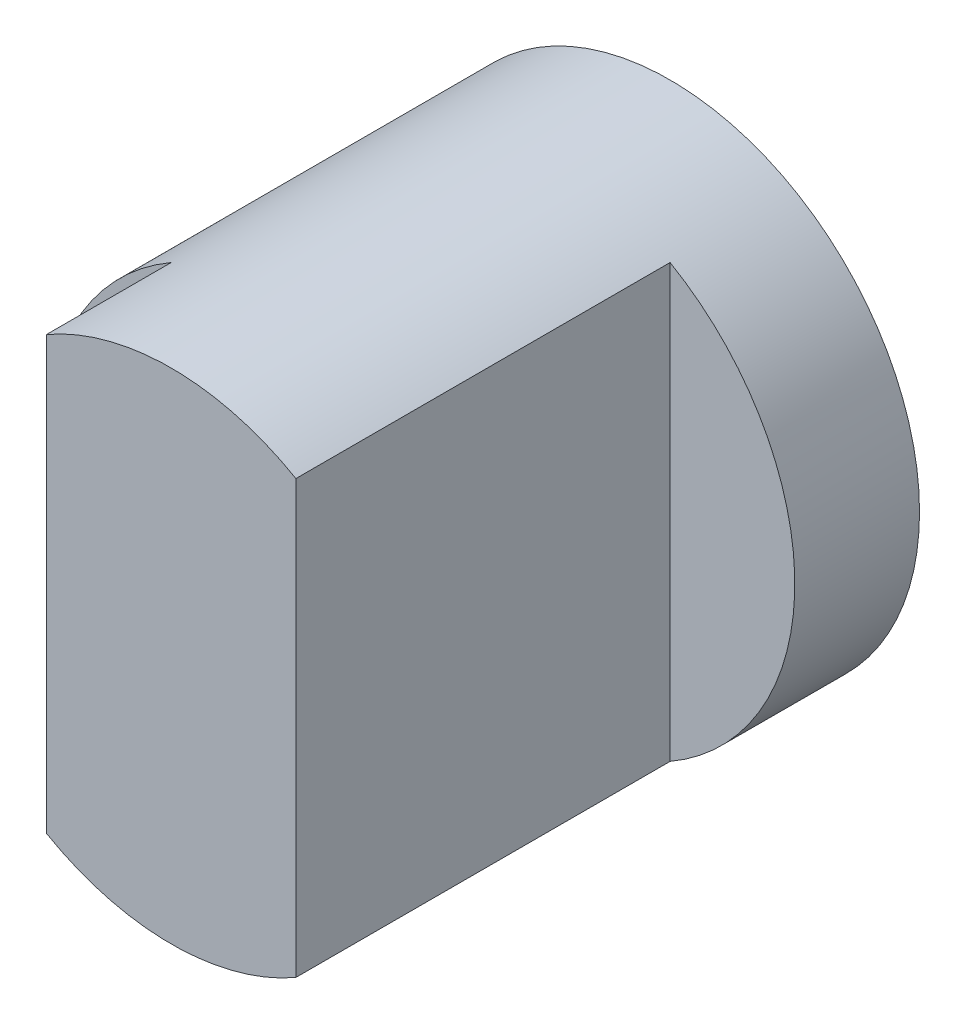
from build123d import *

# Parameters (mm, degrees)
SKETCH1_R           = 2
BOSS_EXTRUDE1_DEPTH = 4
SKETCH2_W           = 1
SKETCH2_H           = 3
SKETCH2_H_2         = 1
CUT_EXTRUDE1_DEPTH  = 5


with BuildPart() as part:
    # Sketch1 → Boss-Extrude1 (new body)
    with BuildSketch(Plane.XY):
        Circle(SKETCH1_R)
    extrude(amount=BOSS_EXTRUDE1_DEPTH)

    # Sketch2 → Cut-Extrude1 (cut, symmetric)
    with BuildSketch(Plane(origin=(0, 0, 0), x_dir=(1, 0, 0), z_dir=(0, 1, 0))):
        with Locations((1.5, -2.5)):
            Rectangle(SKETCH2_W, SKETCH2_H)
        with Locations((-1.5, -3.5)):
            Rectangle(SKETCH2_W, SKETCH2_H_2)
    extrude(amount=CUT_EXTRUDE1_DEPTH, both=True, mode=Mode.SUBTRACT)


solid = part.part
